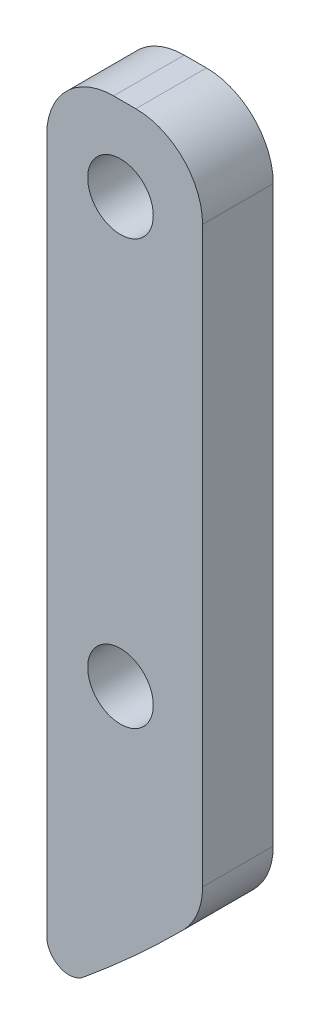
from build123d import *

# Parameters (mm, degrees)
SKETCH1_R           = 1.4732
BOSS_EXTRUDE1_DEPTH = 3.175
FILLET1_R           = 3
FILLET2_R           = 1


with BuildPart() as part:
    # Sketch1 → Boss-Extrude1 (new body)
    with BuildSketch(Plane.XY):
        with BuildLine():
            Line((37.5, -12.587486719), (37.5, -48.86403611))
            ThreePointArc((37.5, -48.86403611), (41.119931518, -45.859516536), (44.5, -42.587486719))
            Line((44.5, -42.587486719), (44.5, -41.365734914))
            Line((44.5, -41.365734914), (44.5, -15.587486719))
            Line((44.5, -15.587486719), (44.5, -12.587486719))
            Line((44.5, -12.587486719), (37.5, -12.587486719))
        make_face()
        with Locations((40.81189221, -16.354311186)):
            Circle(SKETCH1_R, mode=Mode.SUBTRACT)
        with Locations((40.81189221, -35.404311186)):
            Circle(SKETCH1_R, mode=Mode.SUBTRACT)
    extrude(amount=BOSS_EXTRUDE1_DEPTH)

    # Fillet1
    fillet1_edges = [part.edges().sort_by_distance(p)[0] for p in [
        (44.5, -12.587486719, 1.5875),
        (44.5, -42.587486719, 1.5875),
        (37.5, -12.587486719, 1.5875),
    ]]
    fillet(fillet1_edges, radius=FILLET1_R)

    # Fillet2
    fillet2_edges = [part.edges().sort_by_distance(p)[0] for p in [
        (37.5, -48.86403611, 1.5875),
    ]]
    fillet(fillet2_edges, radius=FILLET2_R)


solid = part.part
